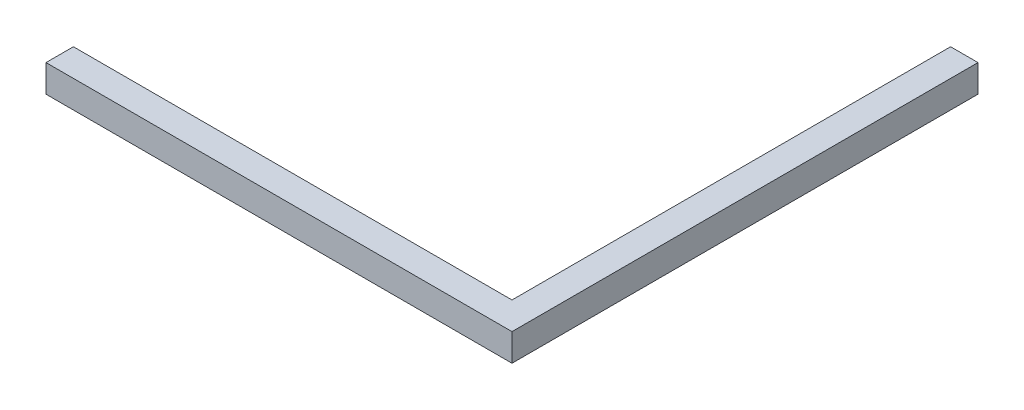
from build123d import *

# Parameters (mm, degrees)
BOSS_EXTRUDE1_DEPTH = 10


with BuildPart() as part:
    # Sketch1 → Boss-Extrude1 (new body)
    with BuildSketch(Plane(origin=(0, 0, 0), x_dir=(1, 0, 0), z_dir=(0, 1, 0))):
        Polygon((-85, -85), (85, -85), (85, 85), (75, 85), (75, -75), (-85, -75), align=None)
    extrude(amount=BOSS_EXTRUDE1_DEPTH)


solid = part.part
